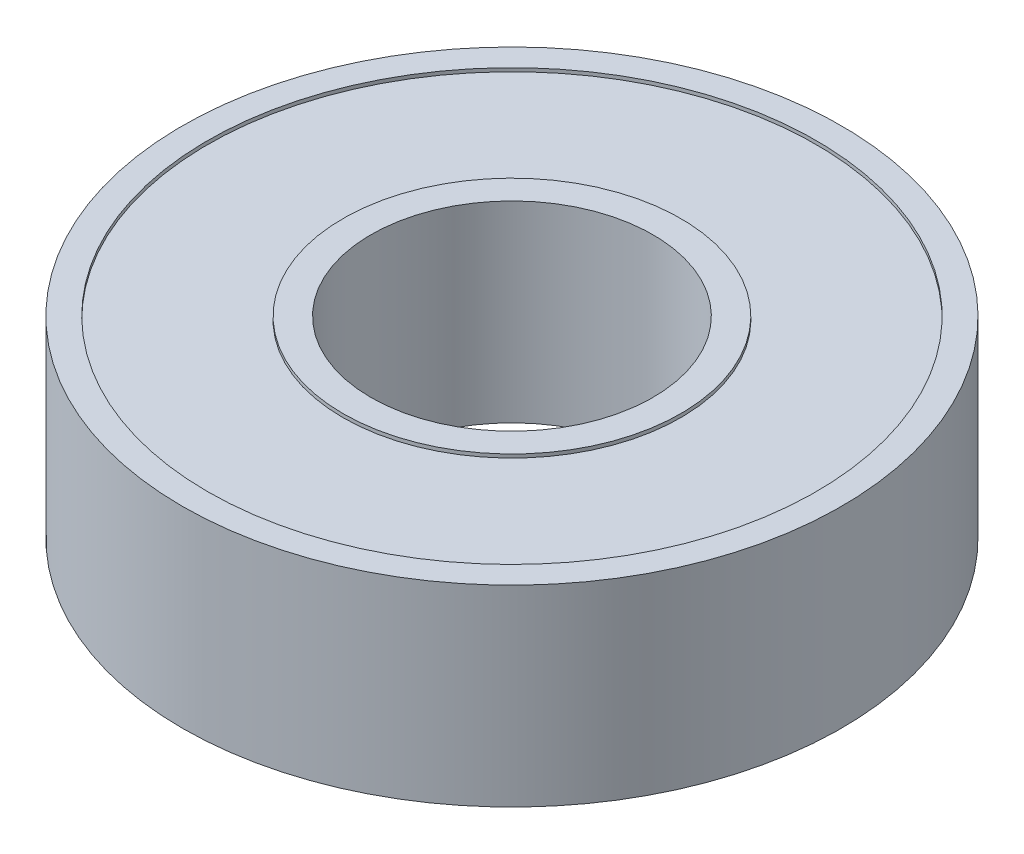
from build123d import *

# Parameters (mm, degrees)
CROQUIS1_R              = 13.975
SALIENTE_EXTRUIR1_DEPTH = 8
CROQUIS2_R              = 5.98
CORTAR_EXTRUIR1_DEPTH   = 8
CROQUIS3_R              = 7.163309877
CROQUIS3_R_2            = 5.98
SALIENTE_EXTRUIR3_DEPTH = 0.15
CROQUIS4_R              = 13.975
CROQUIS4_R_2            = 12.899809837
SALIENTE_EXTRUIR4_DEPTH = 8.15


with BuildPart() as part:
    # Croquis1 → Saliente-Extruir1 (new body)
    with BuildSketch(Plane(origin=(0, 0, 0), x_dir=(1, 0, 0), z_dir=(0, 1, 0))):
        Circle(CROQUIS1_R)
    extrude(amount=SALIENTE_EXTRUIR1_DEPTH)

    # Croquis2 → Cortar-Extruir1 (cut)
    with BuildSketch(Plane(origin=(0, 8, 0), x_dir=(1, 0, 0), z_dir=(0, 1, 0))):
        Circle(CROQUIS2_R)
    extrude(amount=-CORTAR_EXTRUIR1_DEPTH, mode=Mode.SUBTRACT)

    # Croquis3 → Saliente-Extruir3 (add)
    with BuildSketch(Plane(origin=(0, 8, 0), x_dir=(1, 0, 0), z_dir=(0, 1, 0))):
        Circle(CROQUIS3_R)
        Circle(CROQUIS3_R_2, mode=Mode.SUBTRACT)
    extrude(amount=SALIENTE_EXTRUIR3_DEPTH)

    # Croquis4 → Saliente-Extruir4 (add)
    with BuildSketch(Plane(origin=(0, 0, 0), x_dir=(1, 0, 0), z_dir=(0, 1, 0))):
        Circle(CROQUIS4_R)
        Circle(CROQUIS4_R_2, mode=Mode.SUBTRACT)
    extrude(amount=SALIENTE_EXTRUIR4_DEPTH)


solid = part.part
